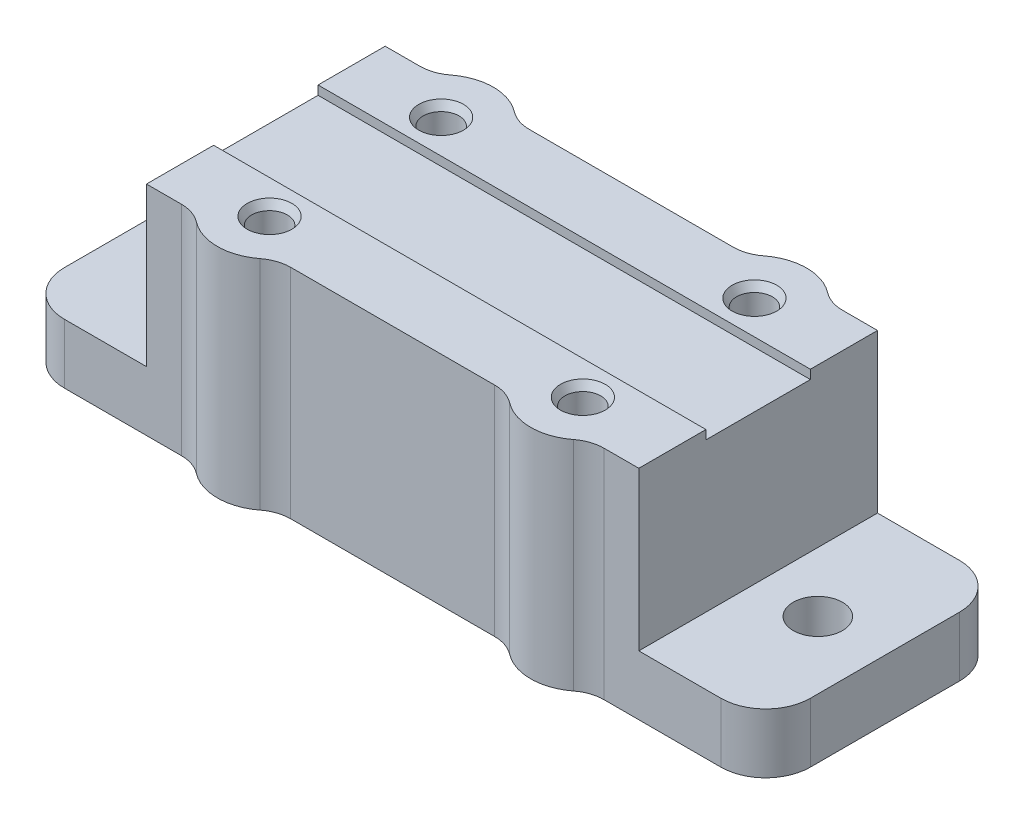
from build123d import *

# Parameters (mm, degrees)
CROQUIS1_W                = 50
CROQUIS1_H                = 16
CROQUIS1_R                = 1.65
SALIENTE_EXTRUIR1_DEPTH   = 4
CROQUIS2_W                = 33
CROQUIS2_H                = 16
SALIENTE_EXTRUIR2_DEPTH   = 10
CROQUIS3_W                = 33
CROQUIS3_H                = 4.5
SALIENTE_EXTRUIR3_DEPTH   = 0.6
CROQUIS4_R                = 1.2
CORTAR_EXTRUIR1_DEPTH     = 8
SALIENTE_EXTRUIR5_DEPTH   = 14.6
SIMETR_A2_COPY_1_DEPTH    = 14.6
REDONDEO1_R               = 3
REDONDEO2_R               = 3
REDONDEO3_R               = 3
REDONDEO4_R               = 3
CROQUIS6_R                = 1.5
CORTAR_EXTRUIR2_DEPTH     = 0.6
CORTAR_EXTRUIR2_TAPER     = 30
SIMETR_A6_COPY_1_SKETCH_R = 1.5
SIMETR_A6_COPY_1_DEPTH    = 0.6
SIMETR_A6_COPY_1_TAPER    = 30


with BuildPart() as part:
    # Croquis1 → Saliente-Extruir1 (new body)
    with BuildSketch(Plane(origin=(0, 0, 0), x_dir=(1, 0, 0), z_dir=(0, 1, 0))):
        with Locations((25, -8)):
            Rectangle(CROQUIS1_W, CROQUIS1_H)
        with Locations((4.5, -8)):
            Circle(CROQUIS1_R, mode=Mode.SUBTRACT)
        with Locations((45.5, -8)):
            Circle(CROQUIS1_R, mode=Mode.SUBTRACT)
    extrude(amount=SALIENTE_EXTRUIR1_DEPTH)

    # Croquis2 → Saliente-Extruir2 (add)
    with BuildSketch(Plane(origin=(0, 4, 0), x_dir=(1, 0, 0), z_dir=(0, 1, 0))):
        with Locations((25, -8)):
            Rectangle(CROQUIS2_W, CROQUIS2_H)
    extrude(amount=SALIENTE_EXTRUIR2_DEPTH)

    # Croquis3 → Saliente-Extruir3 (add)
    with BuildSketch(Plane(origin=(0, 14, 0), x_dir=(1, 0, 0), z_dir=(0, 1, 0))):
        with Locations((25, -2.25)):
            Rectangle(CROQUIS3_W, CROQUIS3_H)
        with Locations((25, -13.75)):
            Rectangle(CROQUIS3_W, CROQUIS3_H)
    extrude(amount=SALIENTE_EXTRUIR3_DEPTH)

    # Croquis4 → Cortar-Extruir1 (cut)
    with BuildSketch(Plane(origin=(0, 14.6, 0), x_dir=(1, 0, 0), z_dir=(0, 1, 0))):
        with Locations((14.5, -13.75)):
            Circle(CROQUIS4_R)
        with Locations((14.5, -2.25)):
            Circle(CROQUIS4_R)
        with Locations((35.5, -13.75)):
            Circle(CROQUIS4_R)
        with Locations((35.5, -2.25)):
            Circle(CROQUIS4_R)
    extrude(amount=-CORTAR_EXTRUIR1_DEPTH, mode=Mode.SUBTRACT)

    # Croquis5 → Saliente-Extruir5 (add)
    with BuildSketch(Plane(origin=(0, 14.6, 0), x_dir=(1, 0, 0), z_dir=(0, 1, 0))):
        with BuildLine():
            Line((18.165719575, -16), (10.834280425, -16))
            ThreePointArc((10.834280425, -16), (11.641151956, -16.133788189), (12.361663581, -16.520833333))
            ThreePointArc((12.361663581, -16.520833333), (14.5, -17.25), (16.638336419, -16.520833333))
            ThreePointArc((16.638336419, -16.520833333), (17.358848044, -16.133788189), (18.165719575, -16))
        make_face()
    saliente_extruir5 = extrude(amount=-SALIENTE_EXTRUIR5_DEPTH)

    # Simetría1: Saliente-Extruir5 across plane
    add(saliente_extruir5.mirror(Plane.ZY.offset(-25)))

    # Simetría2: Saliente-Extruir5 across plane
    add(saliente_extruir5.mirror(Plane.XY.offset(8)))

    # Simetría2 copy 1 sketch → Simetría2 copy 1 (add)
    with BuildSketch(Plane(origin=(50, 14.6, 16), x_dir=(-1, 0, 0), z_dir=(0, 1, 0))):
        with BuildLine():
            Line((18.165719575, -16), (10.834280425, -16))
            ThreePointArc((10.834280425, -16), (11.641151956, -16.133788189), (12.361663581, -16.520833333))
            ThreePointArc((12.361663581, -16.520833333), (14.5, -17.25), (16.638336419, -16.520833333))
            ThreePointArc((16.638336419, -16.520833333), (17.358848044, -16.133788189), (18.165719575, -16))
        make_face()
    extrude(amount=-SIMETR_A2_COPY_1_DEPTH)

    # Redondeo1
    redondeo1_edges = [part.edges().sort_by_distance(p)[0] for p in [
        (0, 2, 16),
    ]]
    fillet(redondeo1_edges, radius=REDONDEO1_R)

    # Redondeo2
    redondeo2_edges = [part.edges().sort_by_distance(p)[0] for p in [
        (0, 2, 0),
    ]]
    fillet(redondeo2_edges, radius=REDONDEO2_R)

    # Redondeo3
    redondeo3_edges = [part.edges().sort_by_distance(p)[0] for p in [
        (50, 2, 0),
    ]]
    fillet(redondeo3_edges, radius=REDONDEO3_R)

    # Redondeo4
    redondeo4_edges = [part.edges().sort_by_distance(p)[0] for p in [
        (50, 2, 16),
    ]]
    fillet(redondeo4_edges, radius=REDONDEO4_R)

    # Croquis6 → Cortar-Extruir2 (cut)
    with BuildSketch(Plane(origin=(0, 14.6, 0), x_dir=(1, 0, 0), z_dir=(0, 1, 0))):
        with Locations((14.5, -13.75)):
            Circle(CROQUIS6_R)
    cortar_extruir2 = extrude(amount=-CORTAR_EXTRUIR2_DEPTH, taper=CORTAR_EXTRUIR2_TAPER, mode=Mode.SUBTRACT)

    # Simetría5: Cortar-Extruir2 across plane
    add(cortar_extruir2.mirror(Plane.ZY.offset(-25)), mode=Mode.SUBTRACT)

    # Simetría6: Cortar-Extruir2 across plane
    add(cortar_extruir2.mirror(Plane.XY.offset(8)), mode=Mode.SUBTRACT)

    # Simetría6 copy 1 sketch → Simetría6 copy 1 (cut)
    with BuildSketch(Plane(origin=(50, 14.6, 16), x_dir=(-1, 0, 0), z_dir=(0, 1, 0))):
        with Locations((14.5, -13.75)):
            Circle(SIMETR_A6_COPY_1_SKETCH_R)
    extrude(amount=-SIMETR_A6_COPY_1_DEPTH, taper=SIMETR_A6_COPY_1_TAPER, mode=Mode.SUBTRACT)


solid = part.part
